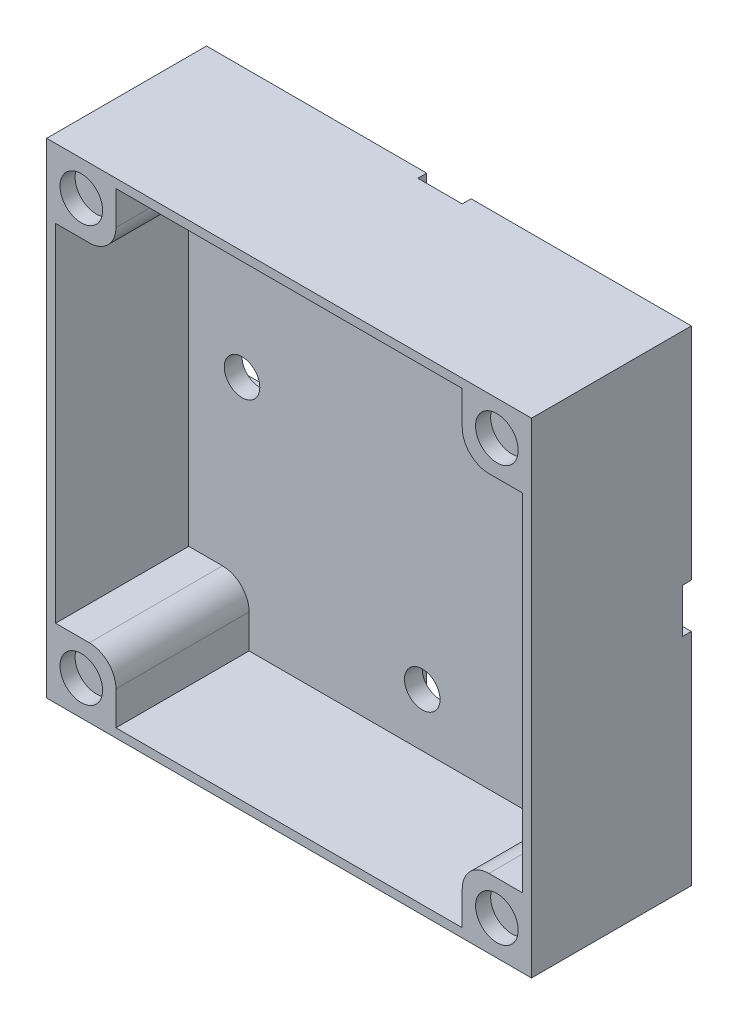
from build123d import *

# Parameters (mm, degrees)
SKICA1_W                 = 54.6
SKICA1_H                 = 54.6
P_IDAT_VYSUNUT_M2_DEPTH  = 3
SKICA5_W                 = 5
SKICA5_H                 = 24.8
SKICA5_W_2               = 54.6
SKICA5_H_2               = 5
ODEBRAT_VYSUNUT_M3_DEPTH = 1
SKICA14_W                = 52.6
SKICA14_H                = 1
P_IDAT_VYSUNUT_M9_DEPTH  = 15
SKICA17_R                = 2
ODEBRAT_VYSUNUT_M8_DEPTH = 7
SKICA19_W                = 7.8
SKICA19_H                = 7.8
P_IDAT_VYSUNUT_M10_DEPTH = 18
SKICA20_R                = 2.4
ODEBRAT_VYSUNUT_M9_DEPTH = 1.7
ZAOBLIT1_R               = 3


with BuildPart() as part:
    # Skica1 → Přidat vysunutím2 (new body)
    with BuildSketch(Plane.XY):
        Rectangle(SKICA1_W, SKICA1_H)
    extrude(amount=P_IDAT_VYSUNUT_M2_DEPTH)

    # Skica5 → Odebrat vysunutím3 (cut)
    with BuildSketch(Plane(origin=(0, 0, 0), x_dir=(-1, 0, 0), z_dir=(0, 0, -1))):
        with Locations((0, 14.9)):
            Rectangle(SKICA5_W, SKICA5_H)
        Rectangle(SKICA5_W_2, SKICA5_H_2)
        with Locations((0, -14.9)):
            Rectangle(SKICA5_W, SKICA5_H)
    extrude(amount=-ODEBRAT_VYSUNUT_M3_DEPTH, mode=Mode.SUBTRACT)

    # Skica14 → Přidat vysunutím9 (add)
    with BuildSketch(Plane.XY.offset(3)):
        Polygon((27.3, 27.3), (-27.3, 27.3), (-27.3, -27.3), (-26.3, -27.3), (-26.3, -26.3), (-26.3, 26.3), (26.3, 26.3), (26.3, -26.3), (26.3, -27.3), (27.3, -27.3), align=None)
        with Locations((0, -26.8)):
            Rectangle(SKICA14_W, SKICA14_H)
    extrude(amount=P_IDAT_VYSUNUT_M9_DEPTH)

    # Skica17 → Odebrat vysunutím8 (cut)
    with BuildSketch(Plane(origin=(0, 0, 1), x_dir=(-1, 0, 0), z_dir=(0, 0, -1))):
        with Locations((-20.3, 0)):
            Circle(SKICA17_R)
        with Locations((20.3, 0)):
            Circle(SKICA17_R)
        with Locations((0, 20.3)):
            Circle(SKICA17_R)
        with Locations((0, -20.3)):
            Circle(SKICA17_R)
    extrude(amount=-ODEBRAT_VYSUNUT_M8_DEPTH, mode=Mode.SUBTRACT)

    # Skica19 → Přidat vysunutím10 (add)
    with BuildSketch(Plane(origin=(0, 0, 0), x_dir=(-1, 0, 0), z_dir=(0, 0, -1))):
        with Locations((-23.4, 23.4)):
            Rectangle(SKICA19_W, SKICA19_H)
        with Locations((23.4, 23.4)):
            Rectangle(SKICA19_W, SKICA19_H)
        with Locations((-23.4, -23.4)):
            Rectangle(SKICA19_W, SKICA19_H)
        with Locations((23.4, -23.4)):
            Rectangle(SKICA19_W, SKICA19_H)
    extrude(amount=-P_IDAT_VYSUNUT_M10_DEPTH)

    # Skica20 → Odebrat vysunutím9 (cut)
    with BuildSketch(Plane.XY.offset(18)):
        with Locations((-23.4, -23.4)):
            Circle(SKICA20_R)
        with Locations((-23.4, 23.4)):
            Circle(SKICA20_R)
        with Locations((23.400280565, 23.4)):
            Circle(SKICA20_R)
        with Locations((23.400280565, -23.4)):
            Circle(SKICA20_R)
    extrude(amount=-ODEBRAT_VYSUNUT_M9_DEPTH, mode=Mode.SUBTRACT)

    # Zaoblit1
    zaoblit1_edges = [part.edges().sort_by_distance(p)[0] for p in [
        (19.5, 19.5, 10.5),
        (-19.5, 19.5, 10.5),
        (19.5, -19.5, 10.5),
        (-19.5, -19.5, 10.5),
    ]]
    fillet(zaoblit1_edges, radius=ZAOBLIT1_R)


solid = part.part
